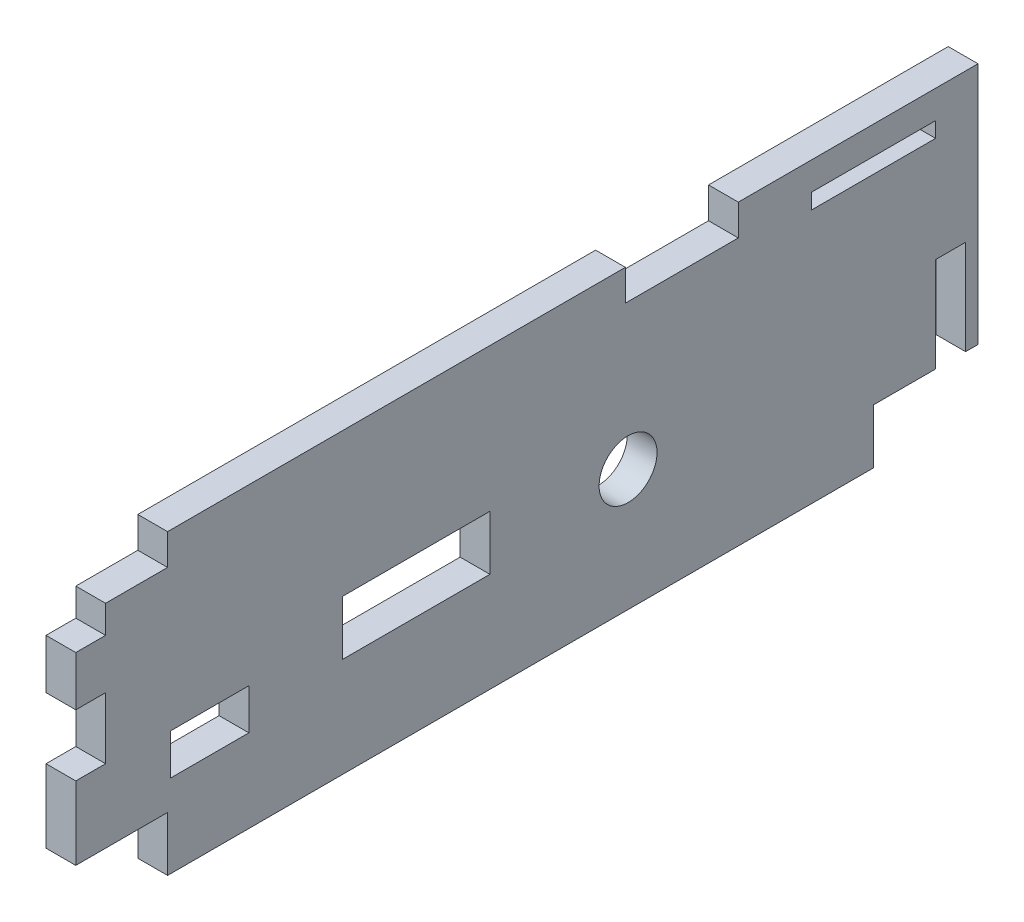
from build123d import *

# Parameters (mm, degrees)
SKETCH2_W                    = 12.7
SKETCH2_H                    = 1.8034
SKETCH2_W_2                  = 8.0391
SKETCH2_H_2                  = 4.1783
SKETCH2_W_3                  = 15.0876
SKETCH2_H_3                  = 5.588
SKETCH2_R                    = 2.96545
BOSS_EXTRUDE1_DEPTH          = 3.048
SKETCH3_W                    = 12.7
SKETCH3_H                    = 0.2286
MADE_HOOD_SLOT_SMALLER_DEPTH = 3.048
SKETCH5_W                    = 3.0734
SKETCH5_H                    = 7.2898
CUT_EXTRUDE1_DEPTH           = 4.048
SKETCH7_W                    = 1.27
SKETCH7_H                    = 2.413
BOSS_EXTRUDE2_DEPTH          = 3.048


with BuildPart() as part:
    # Sketch2 → Boss-Extrude1 (new body)
    with BuildSketch(Plane(origin=(0, 0, 0), x_dir=(0, 0, -1), z_dir=(1, 0, 0))):
        Polygon((6.35, 24.0284), (0, 24.0284), (0, 21.1836), (-3.048, 21.1836), (-3.048, 16.1036), (0, 16.1036), (0, 9.8044), (-3.048, 9.8044), (-3.048, 4.7244), (6.35, 4.7244), (6.35, 1.5494), (46.863, 1.5494), (46.863, 4.7244), (84.963, 4.7244), (84.963, 12.0142), (86.7664, 12.0142), (86.7664, 4.7244), (89.3064, 4.7244), (89.3064, 27.2034), (64.77, 27.2034), (64.77, 24.0284), (53.213, 24.0284), (53.213, 27.2034), (6.35, 27.2034), align=None)
        with Locations((78.613, 23.6601)):
            Rectangle(SKETCH2_W, SKETCH2_H, mode=Mode.SUBTRACT)
        with Locations((10.64895, 7.29615)):
            Rectangle(SKETCH2_W_2, SKETCH2_H_2, mode=Mode.SUBTRACT)
        with Locations((31.8008, 9.7155)):
            Rectangle(SKETCH2_W_3, SKETCH2_H_3, mode=Mode.SUBTRACT)
        with Locations((53.48605, 9.17575)):
            Circle(SKETCH2_R, mode=Mode.SUBTRACT)
    extrude(amount=BOSS_EXTRUDE1_DEPTH)

    # Sketch3 → made hood slot smaller (add)
    with BuildSketch(Plane.ZY):
        with Locations((-78.613, 24.4475)):
            Rectangle(SKETCH3_W, SKETCH3_H)
    extrude(amount=-MADE_HOOD_SLOT_SMALLER_DEPTH)

    # Sketch5 → Cut-Extrude1 (cut, through all)
    with BuildSketch(Plane(origin=(3.048, 0, 0), x_dir=(0, 0, -1), z_dir=(1, 0, 0))):
        with Locations((86.4997, 8.3693)):
            Rectangle(SKETCH5_W, SKETCH5_H)
    extrude(amount=-CUT_EXTRUDE1_DEPTH, mode=Mode.SUBTRACT)

    # Sketch7 → Boss-Extrude2 (add)
    with BuildSketch(Plane(origin=(3.048, 0, 0), x_dir=(0, 0, -1), z_dir=(1, 0, 0))):
        Polygon((-3.048, 4.7244), (-3.048, 2.3114), (6.35, 2.3114), (6.35, -3.2766), (78.613, -3.2766), (78.613, 2.3114), (84.963, 2.3114), (84.963, 4.7244), align=None)
        with Locations((88.6714, 3.5179)):
            Rectangle(SKETCH7_W, SKETCH7_H)
    extrude(amount=-BOSS_EXTRUDE2_DEPTH)


solid = part.part
